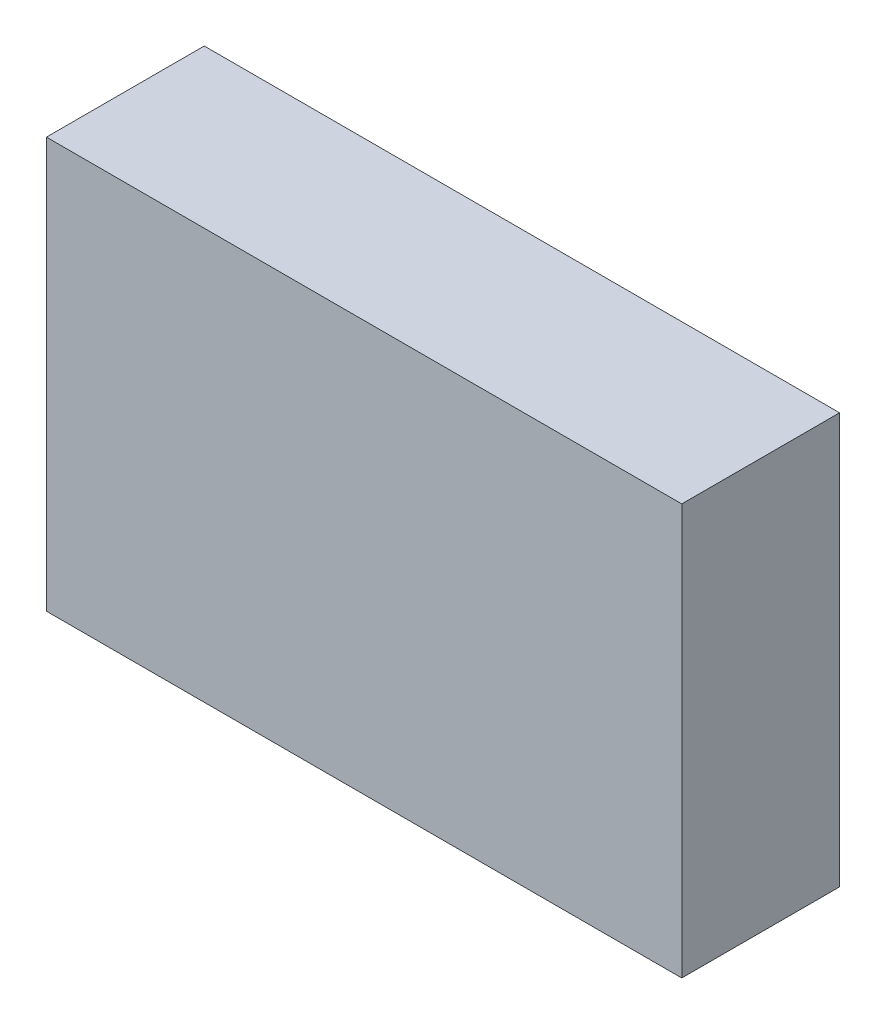
from build123d import *

# Parameters (mm, degrees)
SKETCH1_W           = 62
SKETCH1_H           = 40.068576114
BOSS_EXTRUDE1_DEPTH = 15.4


with BuildPart() as part:
    # Sketch1 → Boss-Extrude1 (new body)
    with BuildSketch(Plane.XY):
        with Locations((0, -1.838413997)):
            Rectangle(SKETCH1_W, SKETCH1_H)
    extrude(amount=BOSS_EXTRUDE1_DEPTH)


solid = part.part
